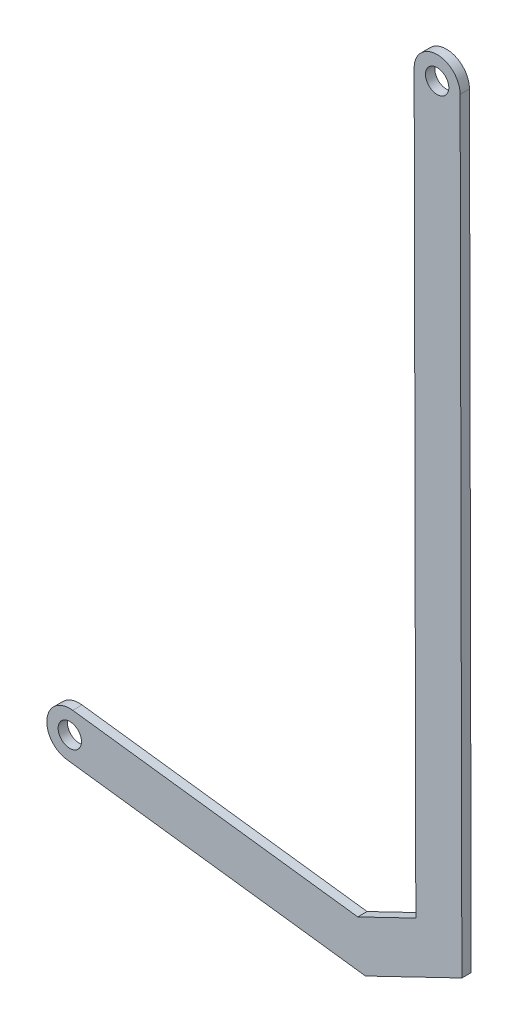
from build123d import *

# Parameters (mm, degrees)
SKETCH1_R           = 3.175
BOSS_EXTRUDE1_DEPTH = 2.54


with BuildPart() as part:
    # Sketch1 → Boss-Extrude1 (new body)
    with BuildSketch(Plane.XY):
        with BuildLine():
            Line((-0.792713517, -6.209589215), (80.497230298, -16.587028851))
            Line((80.497230298, -16.587028851), (106.74595178, -3.93139528))
            Line((106.74595178, -3.93139528), (106.274352446, 204.184578368))
            ThreePointArc((106.274352446, 204.184578368), (100.014368984, 210.444561829), (93.754385523, 204.184578368))
            Line((93.754385523, 204.184578368), (94.208186896, 3.92281412))
            Line((94.208186896, 3.92281412), (78.402076612, -3.697989053))
            Line((78.402076612, -3.697989053), (0.792713517, 6.209589215))
            ThreePointArc((0.792713517, 6.209589215), (-6.209589215, 0.792713517), (-0.792713517, -6.209589215))
        make_face()
        Circle(SKETCH1_R, mode=Mode.SUBTRACT)
        with Locations((100.014368984, 204.184578368)):
            Circle(SKETCH1_R, mode=Mode.SUBTRACT)
    extrude(amount=BOSS_EXTRUDE1_DEPTH)


solid = part.part
